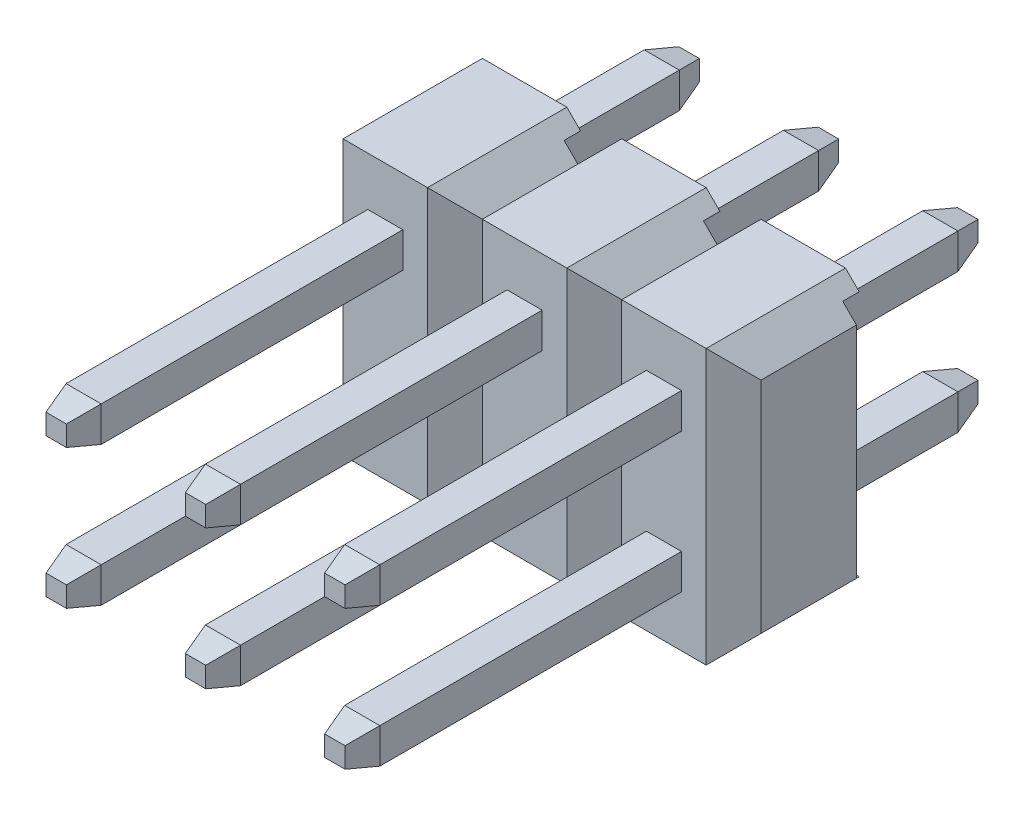
from build123d import *

# Parameters (mm, degrees)
SKETCH2_W             = 2.54
SKETCH2_H             = 5
BOSS_EXTRUDE1_DEPTH   = 2.54
SKETCH3_W             = 0.3
SKETCH3_H             = 4.5
CUT_EXTRUDE1_DEPTH    = 3.54
CHAMFER1_SIZE         = 0.5
CHAMFER2_SIZE         = 0.5
SKETCH4_W             = 0.64
SKETCH4_H             = 0.64
BOSS_EXTRUDE2_DEPTH   = 6
SKETCH6_W             = 0.64
SKETCH6_H             = 0.64
BOSS_EXTRUDE3_DEPTH   = 3.3
CHAMFER3_SIZE         = 0.5
CHAMFER3_SIZE2        = 0.133974596
CHAMFER3_PART_2_SIZE  = 0.5
CHAMFER3_PART_2_SIZE2 = 0.133974596
CHAMFER3_PART_3_SIZE  = 0.5
CHAMFER3_PART_3_SIZE2 = 0.133974596
CHAMFER3_PART_4_SIZE  = 0.5
CHAMFER3_PART_4_SIZE2 = 0.133974596
CHAMFER4_SIZE         = 0.5
CHAMFER4_SIZE2        = 0.133974596
CHAMFER4_PART_2_SIZE  = 0.5
CHAMFER4_PART_2_SIZE2 = 0.133974596
CHAMFER4_PART_3_SIZE  = 0.5
CHAMFER4_PART_3_SIZE2 = 0.133974596
CHAMFER4_PART_4_SIZE  = 0.5
CHAMFER4_PART_4_SIZE2 = 0.133974596
LPATTERN11_COUNT      = 2
LPATTERN11_PITCH      = 2.54
LPATTERN12_COUNT      = 3
LPATTERN12_PITCH      = 2.54
LPATTERN13_COUNT      = 3
LPATTERN13_PITCH      = 2.54


with BuildPart() as part:
    # Sketch2 → Boss-Extrude1 (new body)
    with BuildSketch(Plane.XY):
        with Locations((1.27, 2.5)):
            Rectangle(SKETCH2_W, SKETCH2_H)
    extrude(amount=BOSS_EXTRUDE1_DEPTH)

    # Sketch3 → Cut-Extrude1 (cut, through all)
    with BuildSketch(Plane.ZY):
        with Locations((0.15, 2.5)):
            Rectangle(SKETCH3_W, SKETCH3_H)
    extrude(amount=-CUT_EXTRUDE1_DEPTH, mode=Mode.SUBTRACT)

    # Chamfer1
    chamfer1_edges = [part.edges().sort_by_distance(p)[0] for p in [
        (2.54, 5, 1.27),
        (2.54, 0, 1.27),
        (0, 5, 1.27),
        (0, 0, 1.27),
    ]]
    chamfer(chamfer1_edges, length=CHAMFER1_SIZE)

    # Chamfer2
    chamfer2_edges = [part.edges().sort_by_distance(p)[0] for p in [
        (2.54, 2.5, 2.54),
        (0, 2.5, 2.54),
    ]]
    chamfer(chamfer2_edges, length=CHAMFER2_SIZE)


with BuildPart() as body_2:
    # Sketch4 → Boss-Extrude2 (new body)
    with BuildSketch(Plane.XY.offset(2.54)):
        with Locations((1.27, 1.25)):
            Rectangle(SKETCH4_W, SKETCH4_H)
    extrude(amount=BOSS_EXTRUDE2_DEPTH)

    # Chamfer3
    chamfer3_edges = [body_2.edges().sort_by_distance(p)[0] for p in [
        (1.59, 1.25, 8.54),
    ]]
    chamfer3_side = [body_2.faces().sort_by_distance(p)[0] for p in [
        (1.59, 1.25, 5.54),
    ]]
    chamfer(chamfer3_edges, length=CHAMFER3_SIZE, length2=CHAMFER3_SIZE2, reference=chamfer3_side[0])

    # Chamfer3 part 2
    chamfer3_part_2_edges = [body_2.edges().sort_by_distance(p)[0] for p in [
        (1.27, 1.57, 8.54),
    ]]
    chamfer3_part_2_side = [body_2.faces().sort_by_distance(p)[0] for p in [
        (1.27, 1.57, 5.54),
    ]]
    chamfer(chamfer3_part_2_edges, length=CHAMFER3_PART_2_SIZE, length2=CHAMFER3_PART_2_SIZE2, reference=chamfer3_part_2_side[0])

    # Chamfer3 part 3
    chamfer3_part_3_edges = [body_2.edges().sort_by_distance(p)[0] for p in [
        (0.95, 1.25, 8.54),
    ]]
    chamfer3_part_3_side = [body_2.faces().sort_by_distance(p)[0] for p in [
        (0.95, 1.25, 5.54),
    ]]
    chamfer(chamfer3_part_3_edges, length=CHAMFER3_PART_3_SIZE, length2=CHAMFER3_PART_3_SIZE2, reference=chamfer3_part_3_side[0])

    # Chamfer3 part 4
    chamfer3_part_4_edges = [body_2.edges().sort_by_distance(p)[0] for p in [
        (1.27, 0.93, 8.54),
    ]]
    chamfer3_part_4_side = [body_2.faces().sort_by_distance(p)[0] for p in [
        (1.27, 0.93, 5.54),
    ]]
    chamfer(chamfer3_part_4_edges, length=CHAMFER3_PART_4_SIZE, length2=CHAMFER3_PART_4_SIZE2, reference=chamfer3_part_4_side[0])


with BuildPart() as body_3:
    # Sketch6 → Boss-Extrude3 (new body)
    with BuildSketch(Plane(origin=(0, 0, 0.3), x_dir=(-1, 0, 0), z_dir=(0, 0, -1))):
        with Locations((-1.27, 1.25)):
            Rectangle(SKETCH6_W, SKETCH6_H)
    extrude(amount=BOSS_EXTRUDE3_DEPTH)

    # Chamfer4
    chamfer4_edges = [body_3.edges().sort_by_distance(p)[0] for p in [
        (0.95, 1.25, -3),
    ]]
    chamfer4_side = [body_3.faces().sort_by_distance(p)[0] for p in [
        (0.95, 1.25, -1.35),
    ]]
    chamfer(chamfer4_edges, length=CHAMFER4_SIZE, length2=CHAMFER4_SIZE2, reference=chamfer4_side[0])

    # Chamfer4 part 2
    chamfer4_part_2_edges = [body_3.edges().sort_by_distance(p)[0] for p in [
        (1.27, 1.57, -3),
    ]]
    chamfer4_part_2_side = [body_3.faces().sort_by_distance(p)[0] for p in [
        (1.27, 1.57, -1.35),
    ]]
    chamfer(chamfer4_part_2_edges, length=CHAMFER4_PART_2_SIZE, length2=CHAMFER4_PART_2_SIZE2, reference=chamfer4_part_2_side[0])

    # Chamfer4 part 3
    chamfer4_part_3_edges = [body_3.edges().sort_by_distance(p)[0] for p in [
        (1.59, 1.25, -3),
    ]]
    chamfer4_part_3_side = [body_3.faces().sort_by_distance(p)[0] for p in [
        (1.59, 1.25, -1.35),
    ]]
    chamfer(chamfer4_part_3_edges, length=CHAMFER4_PART_3_SIZE, length2=CHAMFER4_PART_3_SIZE2, reference=chamfer4_part_3_side[0])

    # Chamfer4 part 4
    chamfer4_part_4_edges = [body_3.edges().sort_by_distance(p)[0] for p in [
        (1.27, 0.93, -3),
    ]]
    chamfer4_part_4_side = [body_3.faces().sort_by_distance(p)[0] for p in [
        (1.27, 0.93, -1.35),
    ]]
    chamfer(chamfer4_part_4_edges, length=CHAMFER4_PART_4_SIZE, length2=CHAMFER4_PART_4_SIZE2, reference=chamfer4_part_4_side[0])


with BuildPart() as lpattern11_1:
    # LPattern11: pattern copy
    add(body_3.part.moved(Location(Vector(0, 1, 0) * (1 * LPATTERN11_PITCH))))


with BuildPart() as lpattern11_2:
    # LPattern11: pattern copy
    add(body_2.part.moved(Location(Vector(0, 1, 0) * (1 * LPATTERN11_PITCH))))


with BuildPart() as lpattern12_1:
    # LPattern12: pattern copy
    add(part.part.moved(Location(Vector(-1, 0, 0) * (1 * LPATTERN12_PITCH))))


with BuildPart() as lpattern12_2:
    # LPattern12: pattern copy
    add(part.part.moved(Location(Vector(-1, 0, 0) * (2 * LPATTERN12_PITCH))))


with BuildPart() as lpattern13_1:
    # LPattern13: pattern copy
    add(body_3.part.moved(Location(Vector(-1, 0, 0) * (1 * LPATTERN13_PITCH))))


with BuildPart() as lpattern13_2:
    # LPattern13: pattern copy
    add(body_3.part.moved(Location(Vector(-1, 0, 0) * (2 * LPATTERN13_PITCH))))


with BuildPart() as lpattern13_3:
    # LPattern13: pattern copy
    add(lpattern11_1.part.moved(Location(Vector(-1, 0, 0) * (1 * LPATTERN13_PITCH))))


with BuildPart() as lpattern13_4:
    # LPattern13: pattern copy
    add(lpattern11_1.part.moved(Location(Vector(-1, 0, 0) * (2 * LPATTERN13_PITCH))))


with BuildPart() as lpattern13_5:
    # LPattern13: pattern copy
    add(body_2.part.moved(Location(Vector(-1, 0, 0) * (1 * LPATTERN13_PITCH))))


with BuildPart() as lpattern13_6:
    # LPattern13: pattern copy
    add(body_2.part.moved(Location(Vector(-1, 0, 0) * (2 * LPATTERN13_PITCH))))


with BuildPart() as lpattern13_7:
    # LPattern13: pattern copy
    add(lpattern11_2.part.moved(Location(Vector(-1, 0, 0) * (1 * LPATTERN13_PITCH))))


with BuildPart() as lpattern13_8:
    # LPattern13: pattern copy
    add(lpattern11_2.part.moved(Location(Vector(-1, 0, 0) * (2 * LPATTERN13_PITCH))))


solid = Compound([part.part, body_2.part, body_3.part, lpattern11_1.part, lpattern11_2.part, lpattern12_1.part, lpattern12_2.part, lpattern13_1.part, lpattern13_2.part, lpattern13_3.part, lpattern13_4.part, lpattern13_5.part, lpattern13_6.part, lpattern13_7.part, lpattern13_8.part])
